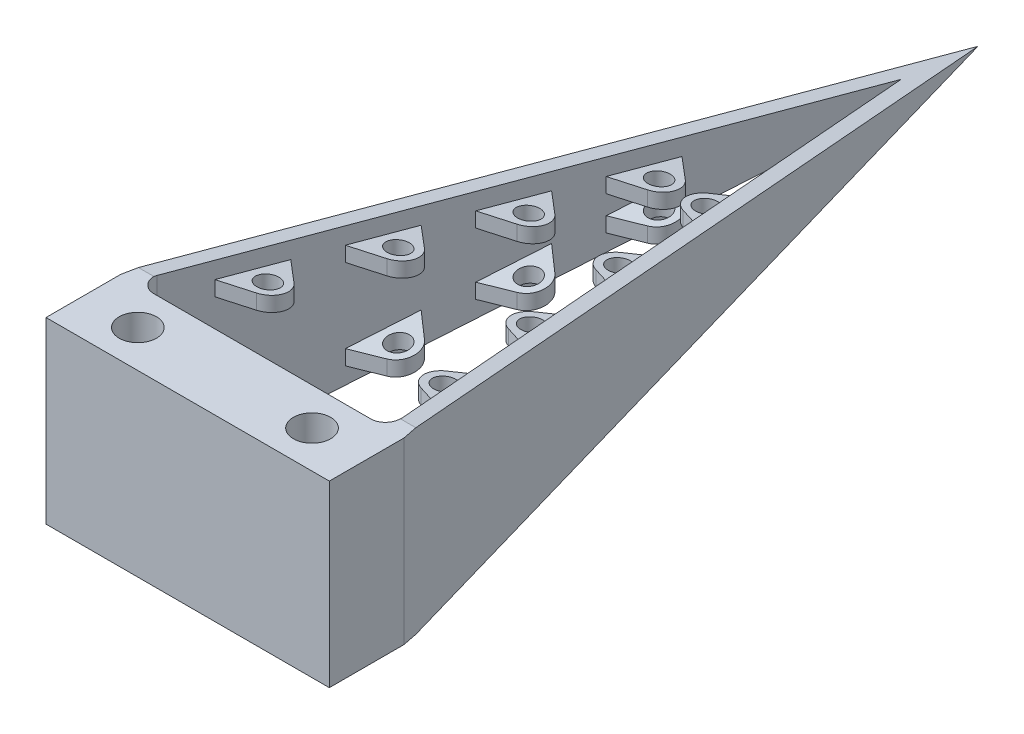
from build123d import *

# Parameters (mm, degrees)
SKETCH1_R                = 3.96875
BOSS_EXTRUDE1_DEPTH      = 34.925
BOSS_EXTRUDE1_DEPTH_BACK = 3.175
FILLET1_R                = 3.175
CUT_EXTRUDE1_DEPTH       = 31.1625
CUT_EXTRUDE1_DEPTH_BACK  = 31.1625
SKETCH3_R                = 2.38125
BOSS_EXTRUDE9_DEPTH      = 3.175
MIRROR22_COPY_1_SKETCH_R = 2.38125
MIRROR22_COPY_1_DEPTH    = 3.175


with BuildPart() as part:
    # Sketch1 → Boss-Extrude1 (new body, two sides)
    with BuildSketch(Plane(origin=(0, 0, 0), x_dir=(1, 0, 0), z_dir=(0, 1, 0))) as boss_extrude1_sk:
        Polygon((0, 152.4), (-30.1625, 0), (-30.1625, -15.875), (30.1625, -15.875), (30.1625, 0), align=None)
        with Locations(Location((-18.542, -7.9375, 0), (0, 0, 270))):  # turned: the seam where the file's is
            Circle(SKETCH1_R, mode=Mode.SUBTRACT)
        with Locations(Location((18.542, -7.9375, 0), (0, 0, 270))):  # turned: the seam where the file's is
            Circle(SKETCH1_R, mode=Mode.SUBTRACT)
        Polygon((-26.925913336, 0), (26.925913336, 0), (0, 136.046720015), align=None, mode=Mode.SUBTRACT)
    extrude(amount=BOSS_EXTRUDE1_DEPTH)
    extrude(boss_extrude1_sk.sketch, amount=-BOSS_EXTRUDE1_DEPTH_BACK)

    # Fillet1
    fillet1_edges = [part.edges().sort_by_distance(p)[0] for p in [
        (-26.925913336, 15.875, 0),
        (26.925913336, 15.875, 0),
    ]]
    fillet(fillet1_edges, radius=FILLET1_R)

    # Sketch2 → Cut-Extrude1 (cut, two sides)
    with BuildSketch(Plane(origin=(0, 0, 0), x_dir=(0, 0, -1), z_dir=(1, 0, 0))) as cut_extrude1_sk:
        Polygon((152.4, 15.875), (3.175, 34.925), (152.4, 34.925), align=None)
        Polygon((3.175, -3.175), (152.4, 15.875), (152.4, -3.175), align=None)
    extrude(amount=CUT_EXTRUDE1_DEPTH, mode=Mode.SUBTRACT)
    extrude(cut_extrude1_sk.sketch, amount=-CUT_EXTRUDE1_DEPTH_BACK, mode=Mode.SUBTRACT)

    # Sketch3 → Boss-Extrude9 (add, along a direction that is not the sketch's normal)
    with BuildSketch(Plane(origin=(0, 0, 0), x_dir=(-1, 0, 0), z_dir=(0, -0.99194978, -0.126631887))):
        with BuildLine():
            Line((-16.21869923, 23.183375104), (-24.161406287, 30.114007256))
            Line((-24.161406287, 30.114007256), (-27.516419153, 13.02479135))
            Line((-27.516419153, 13.02479135), (-17.542962116, 16.438061361))
            ThreePointArc((-17.542962116, 16.438061361), (-14.93362632, 19.428436466), (-16.21869923, 23.183375104))
        make_face()
        with Locations((-18.828035026, 20.193)):
            Circle(SKETCH3_R, mode=Mode.SUBTRACT)
        with BuildLine():
            Line((-22.928734085, 36.39279135), (-19.573721219, 53.482007256))
            Line((-19.573721219, 53.482007256), (-11.631014161, 46.551375104))
            ThreePointArc((-11.631014161, 46.551375104), (-10.345941252, 42.796436466), (-12.955277048, 39.806061361))
            Line((-12.955277048, 39.806061361), (-22.928734085, 36.39279135))
        make_face()
        with Locations((-14.240349958, 43.561)):
            Circle(SKETCH3_R, mode=Mode.SUBTRACT)
        with BuildLine():
            Line((-18.341049017, 59.76079135), (-14.986036151, 76.850007256))
            Line((-14.986036151, 76.850007256), (-7.043329093, 69.919375104))
            ThreePointArc((-7.043329093, 69.919375104), (-5.758256184, 66.164436466), (-8.36759198, 63.174061361))
            Line((-8.36759198, 63.174061361), (-18.341049017, 59.76079135))
        make_face()
        with Locations((-9.652664889, 66.929)):
            Circle(SKETCH3_R, mode=Mode.SUBTRACT)
        with BuildLine():
            Line((-13.753363948, 83.12879135), (-10.398351083, 100.218007256))
            Line((-10.398351083, 100.218007256), (-2.455644025, 93.287375104))
            ThreePointArc((-2.455644025, 93.287375104), (-1.170571116, 89.532436466), (-3.779906912, 86.542061361))
            Line((-3.779906912, 86.542061361), (-13.753363948, 83.12879135))
        make_face()
        with Locations((-5.064979821, 90.297)):
            Circle(SKETCH3_R, mode=Mode.SUBTRACT)
    boss_extrude9 = extrude(amount=-BOSS_EXTRUDE9_DEPTH, dir=(0, -1, 0))

    # Mirror21: Boss-Extrude9 across plane
    add(boss_extrude9.mirror(Plane(origin=(0, 0, 0), x_dir=(0, 0, 1), z_dir=(1, 0, 0))))

    # Mirror22: Boss-Extrude9 across plane
    add(boss_extrude9.mirror(Plane.ZX.offset(15.875)))

    # Mirror22 copy 1 sketch → Mirror22 copy 1 (add, along a direction that is not the sketch's normal)
    with BuildSketch(Plane(origin=(0, 31.75, 0), x_dir=(1, 0, 0), z_dir=(0, 0.99194978, -0.126631887))):
        with BuildLine():
            Line((-16.21869923, 23.183375104), (-24.161406287, 30.114007256))
            Line((-24.161406287, 30.114007256), (-27.516419153, 13.02479135))
            Line((-27.516419153, 13.02479135), (-17.542962116, 16.438061361))
            ThreePointArc((-17.542962116, 16.438061361), (-14.93362632, 19.428436466), (-16.21869923, 23.183375104))
        make_face()
        with Locations((-18.828035026, 20.193)):
            Circle(MIRROR22_COPY_1_SKETCH_R, mode=Mode.SUBTRACT)
        with BuildLine():
            Line((-22.928734085, 36.39279135), (-19.573721219, 53.482007256))
            Line((-19.573721219, 53.482007256), (-11.631014161, 46.551375104))
            ThreePointArc((-11.631014161, 46.551375104), (-10.345941252, 42.796436466), (-12.955277048, 39.806061361))
            Line((-12.955277048, 39.806061361), (-22.928734085, 36.39279135))
        make_face()
        with Locations((-14.240349958, 43.561)):
            Circle(MIRROR22_COPY_1_SKETCH_R, mode=Mode.SUBTRACT)
        with BuildLine():
            Line((-18.341049017, 59.76079135), (-14.986036151, 76.850007256))
            Line((-14.986036151, 76.850007256), (-7.043329093, 69.919375104))
            ThreePointArc((-7.043329093, 69.919375104), (-5.758256184, 66.164436466), (-8.36759198, 63.174061361))
            Line((-8.36759198, 63.174061361), (-18.341049017, 59.76079135))
        make_face()
        with Locations((-9.652664889, 66.929)):
            Circle(MIRROR22_COPY_1_SKETCH_R, mode=Mode.SUBTRACT)
        with BuildLine():
            Line((-13.753363948, 83.12879135), (-10.398351083, 100.218007256))
            Line((-10.398351083, 100.218007256), (-2.455644025, 93.287375104))
            ThreePointArc((-2.455644025, 93.287375104), (-1.170571116, 89.532436466), (-3.779906912, 86.542061361))
            Line((-3.779906912, 86.542061361), (-13.753363948, 83.12879135))
        make_face()
        with Locations((-5.064979821, 90.297)):
            Circle(MIRROR22_COPY_1_SKETCH_R, mode=Mode.SUBTRACT)
    extrude(amount=-MIRROR22_COPY_1_DEPTH, dir=(0, 1, 0))


solid = part.part
